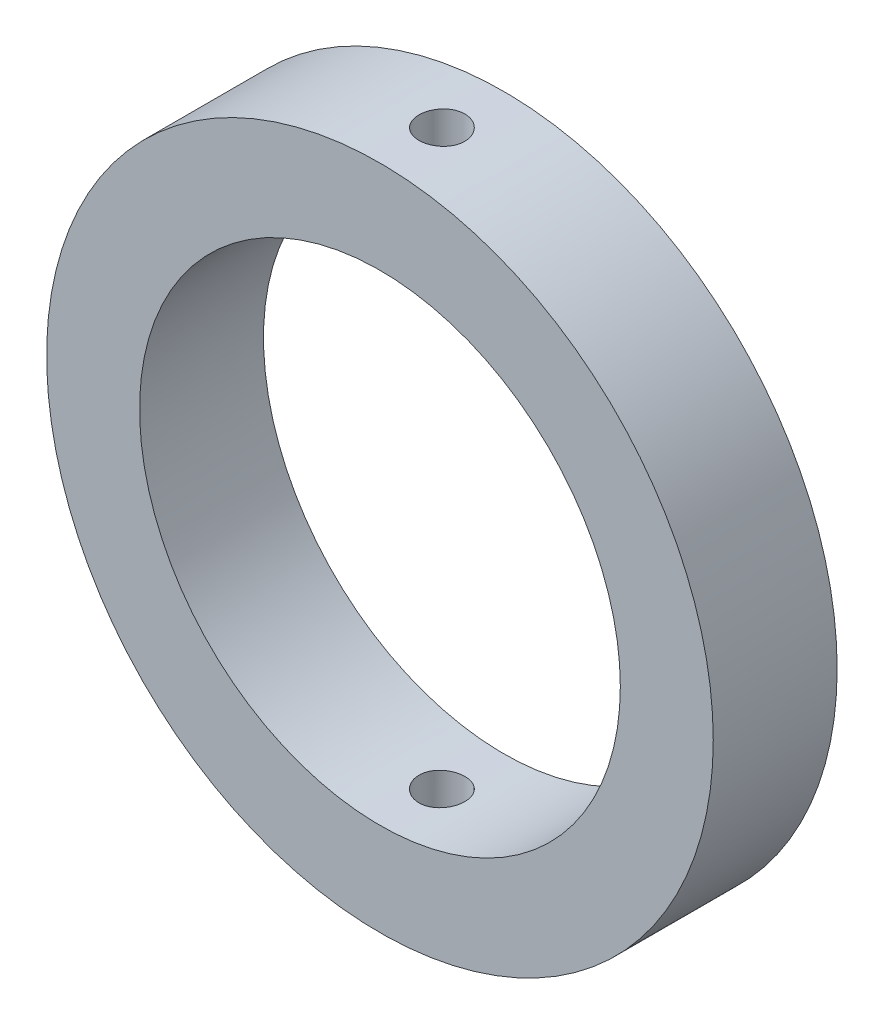
from build123d import *

# Parameters (mm, degrees)
SKETCH1_R               = 68.326
SKETCH1_R_2             = 49.276
BOSS_EXTRUDE1_DEPTH     = 25.4
SKETCH2_R               = 4.699
CUT_EXTRUDE1_DEPTH      = 69.326
CUT_EXTRUDE1_DEPTH_BACK = 69.326


with BuildPart() as part:
    # Sketch1 → Boss-Extrude1 (new body)
    with BuildSketch(Plane.XY):
        Circle(SKETCH1_R)
        Circle(SKETCH1_R_2, mode=Mode.SUBTRACT)
    extrude(amount=BOSS_EXTRUDE1_DEPTH)

    # Sketch2 → Cut-Extrude1 (cut, two sides)
    with BuildSketch(Plane(origin=(0, 0, 0), x_dir=(1, 0, 0), z_dir=(0, 1, 0))) as cut_extrude1_sk:
        with Locations((0, -12.7)):
            Circle(SKETCH2_R)
    extrude(amount=CUT_EXTRUDE1_DEPTH, mode=Mode.SUBTRACT)
    extrude(cut_extrude1_sk.sketch, amount=-CUT_EXTRUDE1_DEPTH_BACK, mode=Mode.SUBTRACT)


solid = part.part
